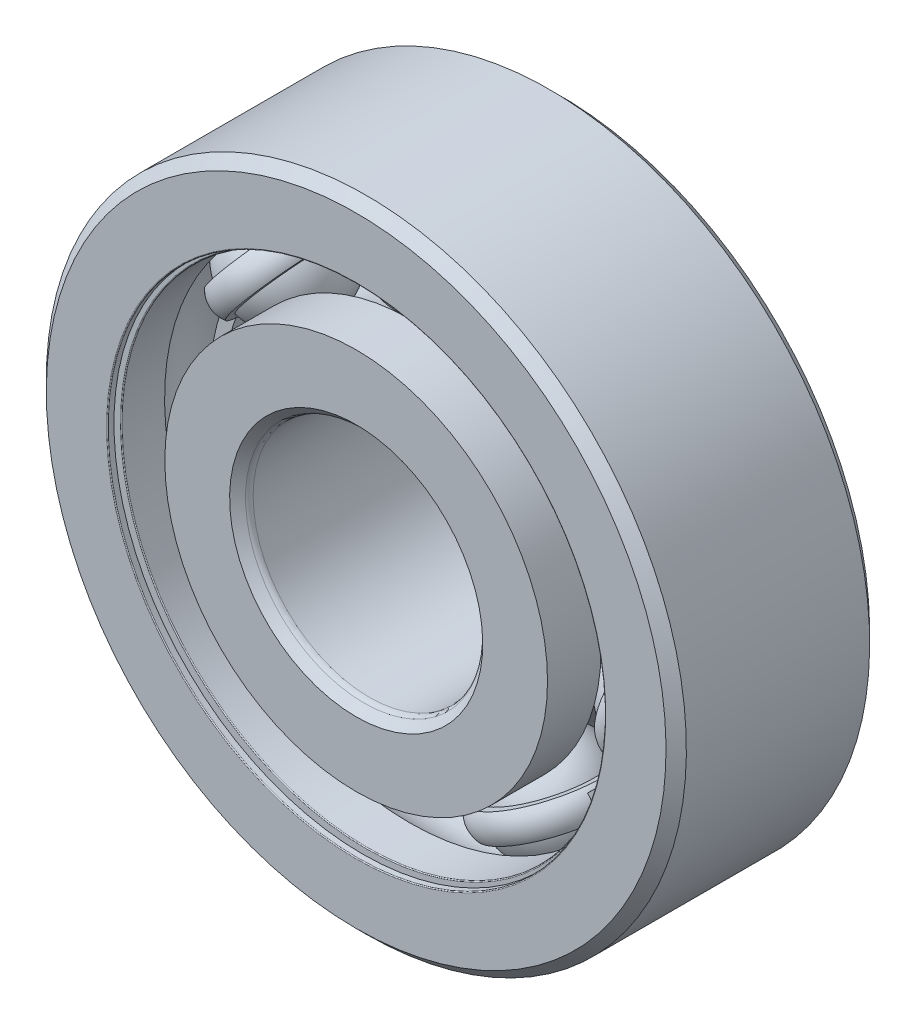
from build123d import *

# Parameters (mm, degrees)
BOSS_EXTRUDE1_DEPTH = 0.583333333
CIRPATTERN1_COUNT   = 7
CIRPATTERN2_COUNT   = 7
FILLET1_R           = 0.0315
FILLET2_R           = 0.2625


with BuildPart() as part:
    # Sketch3 → Revolve1 (revolve)
    with BuildSketch(Plane(origin=(0, 0, 0), x_dir=(0, 0, -1), z_dir=(1, 0, 0))):
        with BuildLine():
            Line((3.15, 11), (3.5, 10.65))
            Line((3.5, 10.65), (3.5, 8.423076923))
            Line((3.5, 8.423076923), (1.6625, 8.423076923))
            ThreePointArc((1.6625, 8.423076923), (0, 9.401572312), (-1.6625, 8.423076923))
            Line((-1.6625, 8.423076923), (-3.5, 8.423076923))
            Line((-3.5, 8.423076923), (-3.5, 10.65))
            Line((-3.5, 10.65), (-3.15, 11))
            Line((-3.15, 11), (3.15, 11))
        make_face()
    revolve(axis=Axis((0, 0, 3.5), (0, 0, -1)))

    # Sketch8 → Cut-Revolve1 (revolve, cut)
    with BuildSketch(Plane(origin=(0, 0, 0), x_dir=(0, 0, -1), z_dir=(1, 0, 0))):
        Polygon((-3.276, 8.423076923), (-3.15, 8.423076923), (-3.15, 9.282051282), (-3.276, 9.282051282), (-3.276, 8.549076923), (-3.5, 8.549076923), (-3.5, 8.423076923), align=None)
        Polygon((3.15, 8.423076923), (3.276, 8.423076923), (3.5, 8.423076923), (3.5, 8.549076923), (3.276, 8.549076923), (3.276, 9.282051282), (3.15, 9.282051282), align=None)
    revolve(axis=Axis((0, 0, 3.5), (0, 0, -1)), mode=Mode.SUBTRACT)

    # Fillet1
    fillet1_edges = [part.edges().sort_by_distance(p)[0] for p in [
        (0, -8.423076923, -3.15),
        (0, -8.549076923, -3.5),
        (0, -8.423076923, 3.15),
        (0, -8.549076923, 3.5),
    ]]
    fillet(fillet1_edges, radius=FILLET1_R)


with BuildPart() as body_2:
    # Sketch4 → Revolve2 (revolve)
    with BuildSketch(Plane(origin=(0, 0, 0), x_dir=(0, 0, -1), z_dir=(1, 0, 0))):
        with BuildLine():
            Line((-3.15, 4), (-3.5, 4.35))
            Line((-3.5, 4.35), (-3.5, 6.576923077))
            Line((-3.5, 6.576923077), (-1.6625, 6.576923077))
            ThreePointArc((-1.6625, 6.576923077), (0, 5.598427688), (1.6625, 6.576923077))
            Line((1.6625, 6.576923077), (3.5, 6.576923077))
            Line((3.5, 6.576923077), (3.5, 4.35))
            Line((3.5, 4.35), (3.15, 4))
            Line((3.15, 4), (-3.15, 4))
        make_face()
    revolve(axis=Axis((0, 0, 3.5), (0, 0, -1)))

    # Fillet2
    fillet2_edges = [body_2.edges().sort_by_distance(p)[0] for p in [
        (0, -4, -3.15),
        (0, -4, 3.15),
    ]]
    fillet(fillet2_edges, radius=FILLET2_R)


with BuildPart() as body_3:
    # Sketch5 → Revolve3 (revolve)
    with BuildSketch(Plane(origin=(0, 0, 0), x_dir=(0, 0, -1), z_dir=(1, 0, 0))):
        with BuildLine():
            Line((-1.901572312, 7.5), (1.901572312, 7.5))
            ThreePointArc((1.901572312, 7.5), (0, 9.401572312), (-1.901572312, 7.5))
        make_face()
    revolve(axis=Axis((0, 7.5, 1.901572312), (0, 0, -1)))


with BuildPart() as body_4:
    # Sketch6 → Revolve4 (revolve)
    with BuildSketch(Plane(origin=(0, 0, 0), x_dir=(0, 0, -1), z_dir=(1, 0, 0))):
        with BuildLine():
            Line((-1.844711225, 7.961538462), (-2.120592688, 7.961538462))
            ThreePointArc((-2.120592688, 7.961538462), (-2.258533419, 7.5), (-2.120592688, 7.038461538))
            Line((-2.120592688, 7.038461538), (-1.844711225, 7.038461538))
            ThreePointArc((-1.844711225, 7.038461538), (-1.901572312, 7.5), (-1.844711225, 7.961538462))
        make_face()
    revolve4 = revolve(axis=Axis((0, 11, 0), (0, -1, 0)))

    # Sketch7 → Boss-Extrude1 (add, symmetric)
    with BuildSketch(Plane.XY):
        with BuildLine():
            Line((5.863736119, 4.676173514), (6.224581418, 4.963938038))
            ThreePointArc((6.224581418, 4.963938038), (3.454382077, 7.173098294), (0, 7.961538462))
            Line((0, 7.961538462), (0, 7.5))
            ThreePointArc((0, 7.5), (3.254128043, 6.757266509), (5.863736119, 4.676173514))
        make_face()
    boss_extrude1 = extrude(amount=BOSS_EXTRUDE1_DEPTH, both=True)

    # CirPattern2: Revolve4, Boss-Extrude1 ×7 about axis
    cirpattern2_axis = Axis((0, 0, 3.5), (0, 0, -1))
    add([revolve4.rotate(cirpattern2_axis, i * 360 / CIRPATTERN2_COUNT) for i in range(1, CIRPATTERN2_COUNT)])
    add([boss_extrude1.rotate(cirpattern2_axis, i * 360 / CIRPATTERN2_COUNT) for i in range(1, CIRPATTERN2_COUNT)])


with BuildPart() as cirpattern1_1:
    # CirPattern1: pattern copy
    add(body_3.part.rotate(Axis((0, 0, 3.5), (0, 0, -1)), 1 * 360 / CIRPATTERN1_COUNT))


with BuildPart() as cirpattern1_2:
    # CirPattern1: pattern copy
    add(body_3.part.rotate(Axis((0, 0, 3.5), (0, 0, -1)), 2 * 360 / CIRPATTERN1_COUNT))


with BuildPart() as cirpattern1_3:
    # CirPattern1: pattern copy
    add(body_3.part.rotate(Axis((0, 0, 3.5), (0, 0, -1)), 3 * 360 / CIRPATTERN1_COUNT))


with BuildPart() as cirpattern1_4:
    # CirPattern1: pattern copy
    add(body_3.part.rotate(Axis((0, 0, 3.5), (0, 0, -1)), 4 * 360 / CIRPATTERN1_COUNT))


with BuildPart() as cirpattern1_5:
    # CirPattern1: pattern copy
    add(body_3.part.rotate(Axis((0, 0, 3.5), (0, 0, -1)), 5 * 360 / CIRPATTERN1_COUNT))


with BuildPart() as cirpattern1_6:
    # CirPattern1: pattern copy
    add(body_3.part.rotate(Axis((0, 0, 3.5), (0, 0, -1)), 6 * 360 / CIRPATTERN1_COUNT))


solid = Compound([part.part, body_2.part, body_3.part, body_4.part, cirpattern1_1.part, cirpattern1_2.part, cirpattern1_3.part, cirpattern1_4.part, cirpattern1_5.part, cirpattern1_6.part])
